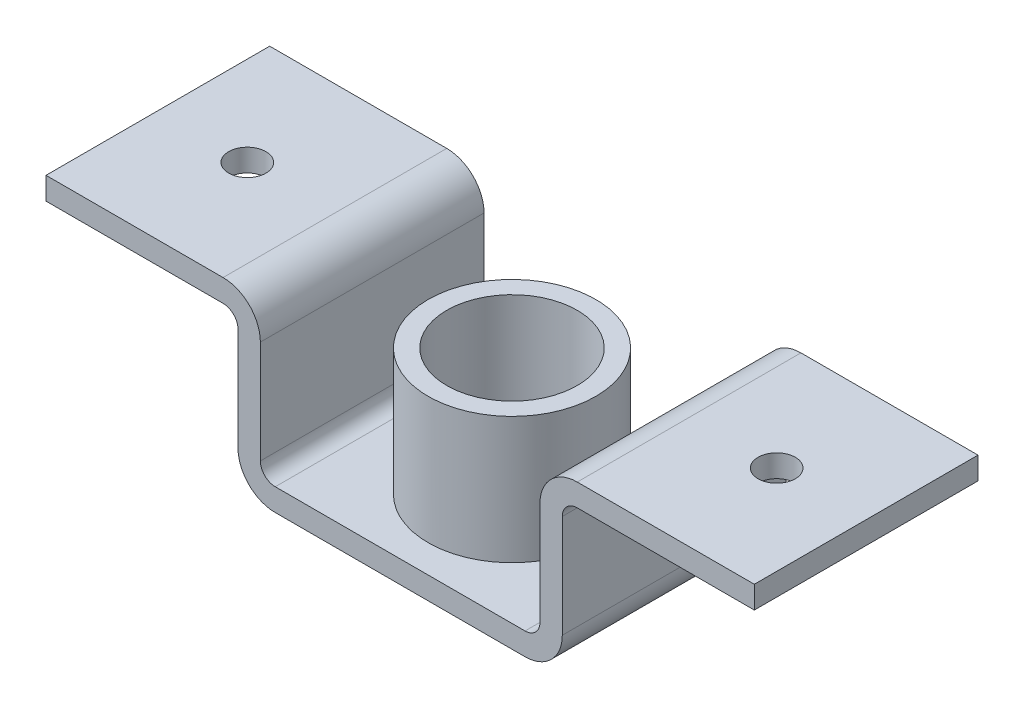
from build123d import *

# Parameters (mm, degrees)
BOSS_EXTRUDE1_DEPTH = 300
SKETCH3_R           = 25
CUT_EXTRUDE2_DEPTH  = 239
LPATTERN1_COUNT     = 2
LPATTERN1_PITCH     = 710
SKETCH4_R           = 112.5
SKETCH4_R_2         = 87.5
BOSS_EXTRUDE2_DEPTH = 170
SKETCH5_R           = 37.5
CUT_EXTRUDE3_DEPTH  = 170


with BuildPart() as part:
    # Sketch1 → Boss-Extrude1 (new body)
    with BuildSketch(Plane.XY):
        with BuildLine():
            Line((0, 0), (-167.5, 0))
            ThreePointArc((-167.5, 0), (-202.855339059, 14.644660941), (-217.5, 50))
            Line((-217.5, 50), (-217.5, 188))
            ThreePointArc((-217.5, 188), (-223.357864376, 202.142135624), (-237.5, 208))
            Line((-237.5, 208), (-475, 208))
            Line((-475, 208), (-475, 238))
            Line((-475, 238), (-237.5, 238))
            ThreePointArc((-237.5, 238), (-202.144660941, 223.355339059), (-187.5, 188))
            Line((-187.5, 188), (-187.5, 50))
            ThreePointArc((-187.5, 50), (-181.642135624, 35.857864376), (-167.5, 30))
            Line((-167.5, 30), (0, 30))
            Line((0, 30), (167.5, 30))
            ThreePointArc((167.5, 30), (181.642135624, 35.857864376), (187.5, 50))
            Line((187.5, 50), (187.5, 188))
            ThreePointArc((187.5, 188), (202.144660941, 223.355339059), (237.5, 238))
            Line((237.5, 238), (475, 238))
            Line((475, 238), (475, 208))
            Line((475, 208), (237.494317451, 208))
            ThreePointArc((237.494317451, 208), (223.35419134, 202.144144851), (217.494318258, 188.005683357))
            Line((217.494318258, 188.005683357), (217.455097442, 49.985791608))
            ThreePointArc((217.455097442, 49.985791608), (202.805414738, 14.639637872), (167.455099461, 0))
            Line((167.455099461, 0), (0, 0))
        make_face()
    extrude(amount=BOSS_EXTRUDE1_DEPTH)

    # Sketch3 → Cut-Extrude2 (cut, through all)
    with BuildSketch(Plane(origin=(0, 238, 0), x_dir=(1, 0, 0), z_dir=(0, 1, 0))):
        with Locations(Location((355, -150, 0), (0, 0, 180))):  # turned: the seam where the file's is
            Circle(SKETCH3_R)
    cut_extrude2 = extrude(amount=-CUT_EXTRUDE2_DEPTH, mode=Mode.SUBTRACT)

    # LPattern1: Cut-Extrude2 ×2
    with Locations(*[(-i * LPATTERN1_PITCH, 0, 0) for i in range(1, LPATTERN1_COUNT)]):
        add(cut_extrude2, mode=Mode.SUBTRACT)

    # Sketch4 → Boss-Extrude2 (add)
    with BuildSketch(Plane(origin=(0, 30, 0), x_dir=(1, 0, 0), z_dir=(0, 1, 0))):
        with Locations((0, -150)):
            Circle(SKETCH4_R)
        with Locations(Location((0, -150, 0), (0, 0, 180))):  # turned: the seam where the file's is
            Circle(SKETCH4_R_2, mode=Mode.SUBTRACT)
    extrude(amount=BOSS_EXTRUDE2_DEPTH)

    # Sketch5 → Cut-Extrude3 (cut)
    with BuildSketch(Plane(origin=(0, 30, 0), x_dir=(1, 0, 0), z_dir=(0, 1, 0))):
        with Locations(Location((0, -150, 0), (0, 0, 180))):  # turned: the seam where the file's is
            Circle(SKETCH5_R)
    extrude(amount=-CUT_EXTRUDE3_DEPTH, mode=Mode.SUBTRACT)


solid = part.part
